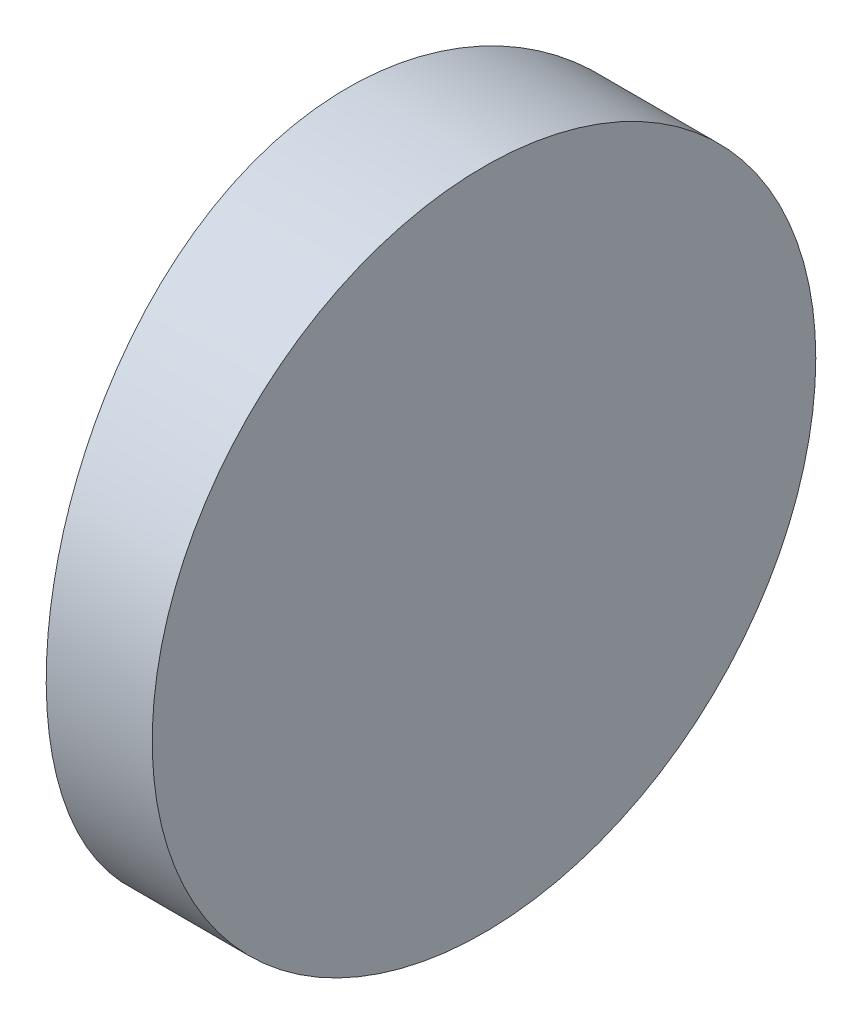
from build123d import *

# Parameters (mm, degrees)
EXTRUDE_1_DEPTH     = 12.5
CUT_EXTRUDE_8_DEPTH = 12.7


with BuildPart() as part:
    # 草图1 → 凸台-拉伸1 (new body)
    with BuildSketch(Plane(origin=(0, 0, 0), x_dir=(1, 0, 0), z_dir=(0, 1, 0))):
        with BuildLine():
            Line((-29.451923612, 6.25), (-27.454795665, 6.25))
            Line((-27.454795665, 6.25), (-27.454795665, -6.25))
            Line((-27.454795665, -6.25), (-29.451923612, -6.25))
            ThreePointArc((-29.451923612, -6.25), (-30.024795665, 0), (-29.451923612, 6.25))
        make_face()
    extrude(amount=EXTRUDE_1_DEPTH)

    # 草图2 → 切除-拉伸8 (cut)
    with BuildSketch(Plane(origin=(-27.454795665, 0, 0), x_dir=(0, 0, -1), z_dir=(1, 0, 0))):
        with BuildLine():
            Line((-6.25, 12.5), (-6.25, 6.249999987))
            ThreePointArc((-6.25, 6.249999987), (-4.419417387, 10.669417378), (0, 12.5))
            Line((0, 12.5), (-6.25, 12.5))
        make_face()
        with BuildLine():
            ThreePointArc((0, 12.5), (4.419417382, 10.669417382), (6.25, 6.25))
            Line((6.25, 6.25), (6.25, 12.5))
            Line((6.25, 12.5), (0, 12.5))
        make_face()
        with BuildLine():
            ThreePointArc((6.25, 6.25), (4.419417382, 1.830582618), (0, 0))
            Line((0, 0), (6.25, 0))
            Line((6.25, 0), (6.25, 6.25))
        make_face()
        with BuildLine():
            Line((-6.25, 6.249999987), (-6.25, 0))
            Line((-6.25, 0), (0, 0))
            ThreePointArc((0, 0), (-4.419417378, 1.830582613), (-6.25, 6.249999987))
        make_face()
    extrude(amount=-CUT_EXTRUDE_8_DEPTH, mode=Mode.SUBTRACT)


solid = part.part
